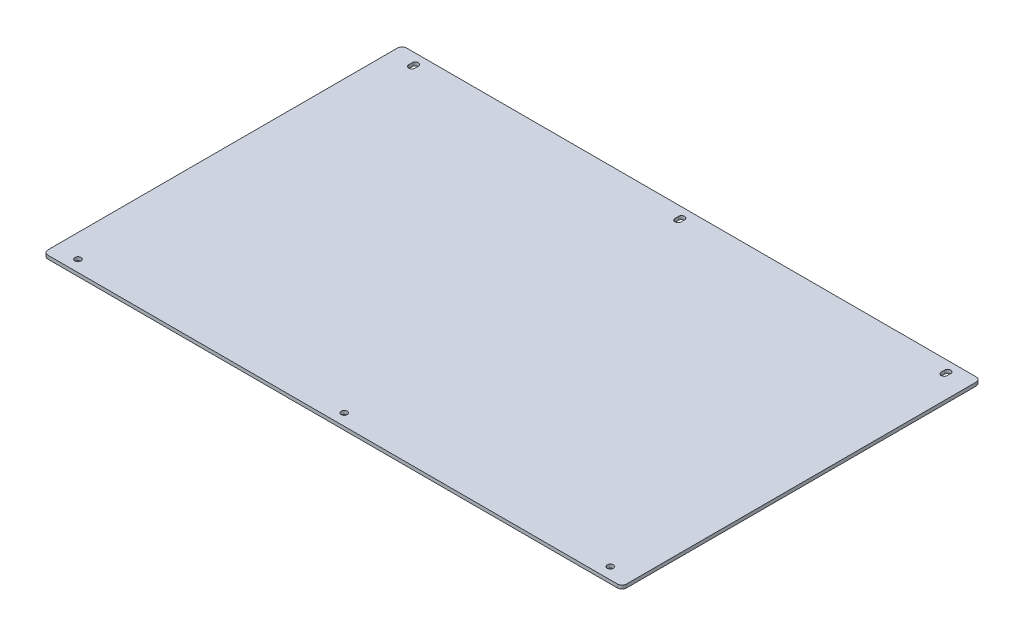
from build123d import *

# Parameters (mm, degrees)
SKETCH1_W                  = 500
SKETCH1_H                  = 310
BOSS_EXTRUDE1_DEPTH        = 3
FILLET1_R                  = 4
F_5_3_5_3_DIAMETER_HOLE1_D = 5.3
CUT_EXTRUDE1_DEPTH         = 4


with BuildPart() as part:
    # Sketch1 → Boss-Extrude1 (new body)
    with BuildSketch(Plane(origin=(0, 0, 0), x_dir=(1, 0, 0), z_dir=(0, 1, 0))):
        Rectangle(SKETCH1_W, SKETCH1_H)
    extrude(amount=BOSS_EXTRUDE1_DEPTH)

    # Fillet1
    fillet1_edges = [part.edges().sort_by_distance(p)[0] for p in [
        (250, 1.5, 155),
        (-250, 1.5, 155),
        (-250, 1.5, -155),
        (250, 1.5, -155),
    ]]
    fillet(fillet1_edges, radius=FILLET1_R)

    # Ø5.3 (5.3) Diameter Hole1 (through all)
    with Locations(Plane(origin=(0, 3, 0), x_dir=(1, 0, 0), z_dir=(0, 1, 0))):
        with Locations((230, 145), (-230, -145), (-230, 145), (230, -145), (0, 145), (0, -145)):
            Hole(F_5_3_5_3_DIAMETER_HOLE1_D / 2)

    # Sketch6 → Cut-Extrude1 (cut, through all)
    with BuildSketch(Plane(origin=(0, 3, 0), x_dir=(1, 0, 0), z_dir=(0, 1, 0))):
        with BuildLine():
            Line((-232.65, 143.5), (-232.65, 146.5))
            ThreePointArc((-232.65, 146.5), (-230, 149.15), (-227.35, 146.5))
            Line((-227.35, 146.5), (-227.35, 143.5))
            ThreePointArc((-227.35, 143.5), (-230, 140.85), (-232.65, 143.5))
        make_face()
        with BuildLine():
            Line((-2.65, 143.5), (-2.65, 146.5))
            ThreePointArc((-2.65, 146.5), (0, 149.15), (2.65, 146.5))
            Line((2.65, 146.5), (2.65, 143.5))
            ThreePointArc((2.65, 143.5), (0, 140.85), (-2.65, 143.5))
        make_face()
        with BuildLine():
            Line((227.35, 143.5), (227.35, 146.5))
            ThreePointArc((227.35, 146.5), (230, 149.15), (232.65, 146.5))
            Line((232.65, 146.5), (232.65, 143.5))
            ThreePointArc((232.65, 143.5), (230, 140.85), (227.35, 143.5))
        make_face()
    extrude(amount=-CUT_EXTRUDE1_DEPTH, mode=Mode.SUBTRACT)


solid = part.part
